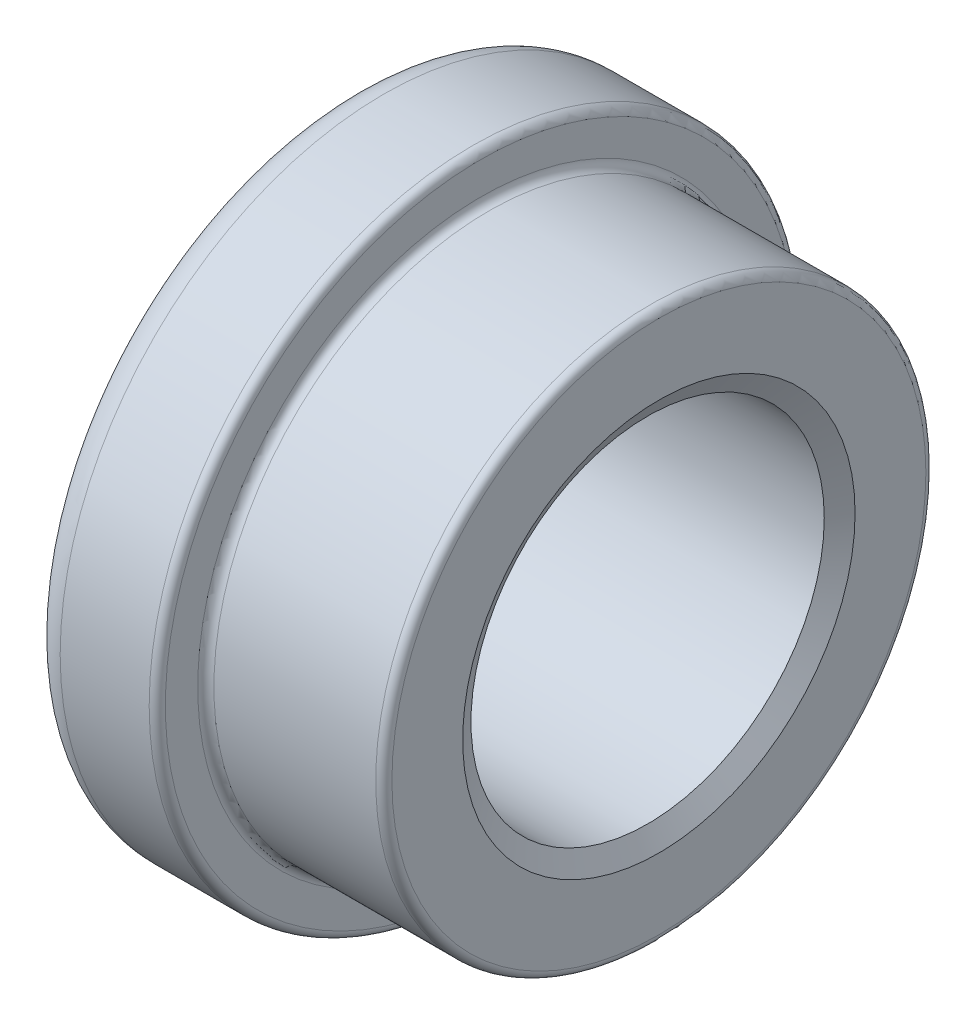
from build123d import *


with BuildPart() as part:
    # Sketch1 → Base-Revolve (revolve)
    with BuildSketch(Plane.XY):
        with BuildLine():
            Line((0, 12.125), (0, 16.5))
            ThreePointArc((0, 16.5), (-0.146446609, 16.853553391), (-0.5, 17))
            Line((-0.5, 17), (-10.5, 17))
            ThreePointArc((-10.5, 17), (-10.853553391, 17.146446609), (-11, 17.5))
            Line((-11, 17.5), (-11, 19.5))
            ThreePointArc((-11, 19.5), (-11.146446609, 19.853553391), (-11.5, 20))
            Line((-11.5, 20), (-17, 20))
            ThreePointArc((-17, 20), (-18.414213562, 19.414213562), (-19, 18))
            Line((-19, 18), (-19, 12.125))
            Line((-19, 12.125), (-18.30284955, 10.9175))
            Line((-18.30284955, 10.9175), (-0.69715045, 10.9175))
            Line((-0.69715045, 10.9175), (0, 12.125))
        make_face()
    revolve(axis=Axis((0, 0, 0), (-1, 0, 0)))


solid = part.part
